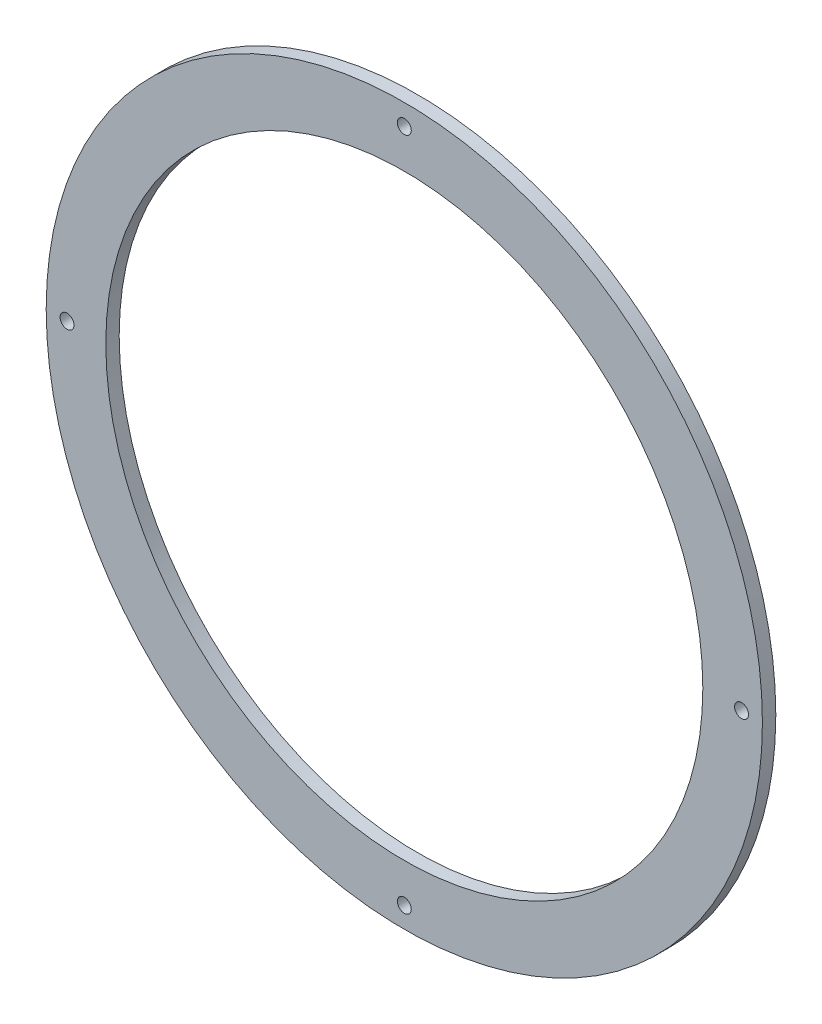
from build123d import *

# Parameters (mm, degrees)
SKETCH1_R           = 84.93125
SKETCH1_R_2         = 70.79484504
BOSS_EXTRUDE1_DEPTH = 3.175
SKETCH2_R           = 1.651
CUT_EXTRUDE1_DEPTH  = 3.175


with BuildPart() as part:
    # Sketch1 → Boss-Extrude1 (new body)
    with BuildSketch(Plane.XY):
        Circle(SKETCH1_R)
        Circle(SKETCH1_R_2, mode=Mode.SUBTRACT)
    extrude(amount=BOSS_EXTRUDE1_DEPTH)

    # Sketch2 → Cut-Extrude1 (cut)
    with BuildSketch(Plane.XY.offset(3.175)):
        with Locations((0, -79.97825)):
            Circle(SKETCH2_R)
        with Locations((-79.97825, 0)):
            Circle(SKETCH2_R)
        with Locations((0, 79.97825)):
            Circle(SKETCH2_R)
        with Locations((79.97825, 0)):
            Circle(SKETCH2_R)
    extrude(amount=-CUT_EXTRUDE1_DEPTH, mode=Mode.SUBTRACT)


solid = part.part
